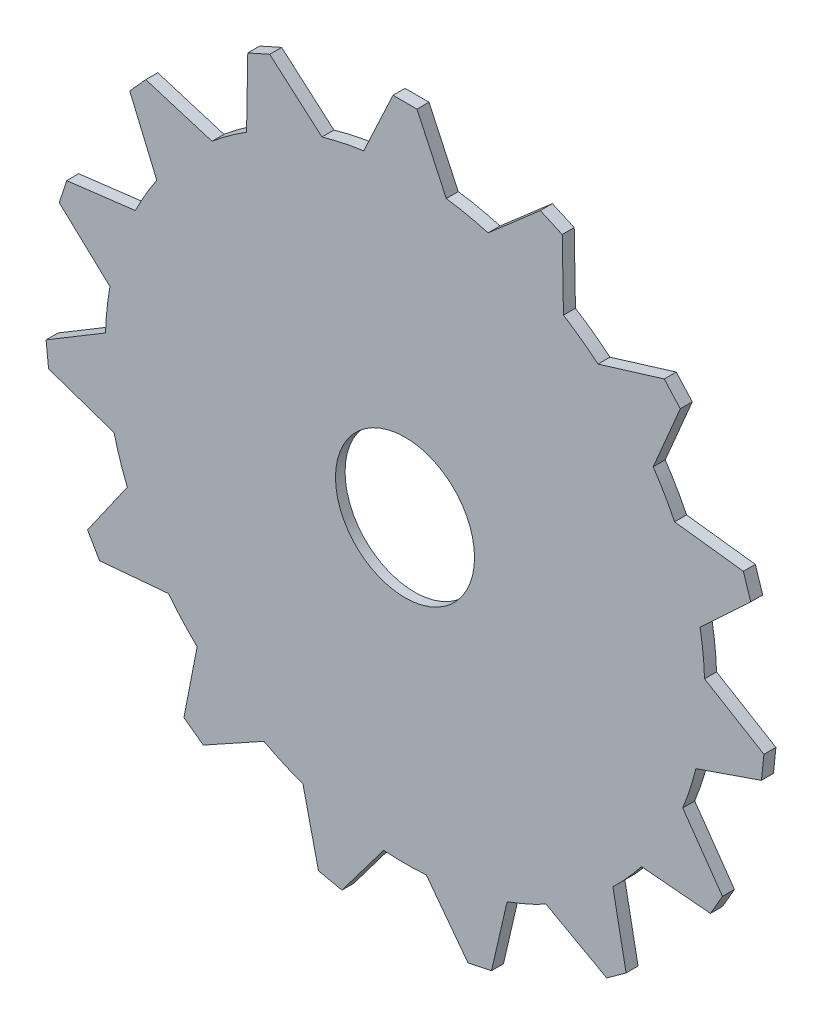
from build123d import *

# Parameters (mm, degrees)
SKETCH1_R           = 31.75
BOSS_EXTRUDE1_DEPTH = 1.27
BOSS_EXTRUDE2_DEPTH = 1.27
SKETCH3_R           = 7.366
CUT_EXTRUDE1_DEPTH  = 10
CIRPATTERN1_COUNT   = 15
SKETCH4_R           = 25.4
CUT_EXTRUDE2_DEPTH  = 0.254


with BuildPart() as part:
    # Sketch1 → Boss-Extrude1 (new body)
    with BuildSketch(Plane.XY):
        Circle(SKETCH1_R)
    extrude(amount=BOSS_EXTRUDE1_DEPTH)

    # Sketch2 → Boss-Extrude2 (add)
    with BuildSketch(Plane.XY.offset(1.27)):
        with BuildLine():
            Line((-1.27, 38.1), (1.27, 38.1))
            Line((1.27, 38.1), (4.372096767, 31.447532015))
            ThreePointArc((4.372096767, 31.447532015), (0, 31.75), (-4.372096767, 31.447532015))
            Line((-4.372096767, 31.447532015), (-1.27, 38.1))
        make_face()
    boss_extrude2 = extrude(amount=-BOSS_EXTRUDE2_DEPTH)

    # Sketch3 → Cut-Extrude1 (cut)
    with BuildSketch(Plane(origin=(0, 0, 0), x_dir=(-1, 0, 0), z_dir=(0, 0, -1))):
        Circle(SKETCH3_R)
    extrude(amount=-CUT_EXTRUDE1_DEPTH, mode=Mode.SUBTRACT)

    # CirPattern1: Boss-Extrude2 ×15 about axis
    cirpattern1_axis = Axis((0, 0, 0), (0, 0, 1))
    for i in range(1, CIRPATTERN1_COUNT):
        add(boss_extrude2.rotate(cirpattern1_axis, i * 360 / CIRPATTERN1_COUNT))

    # Sketch4 → Cut-Extrude2 (cut)
    with BuildSketch(Plane(origin=(0, 0, 0), x_dir=(-1, 0, 0), z_dir=(0, 0, -1))):
        Circle(SKETCH4_R)
    extrude(amount=-CUT_EXTRUDE2_DEPTH, mode=Mode.SUBTRACT)


solid = part.part
